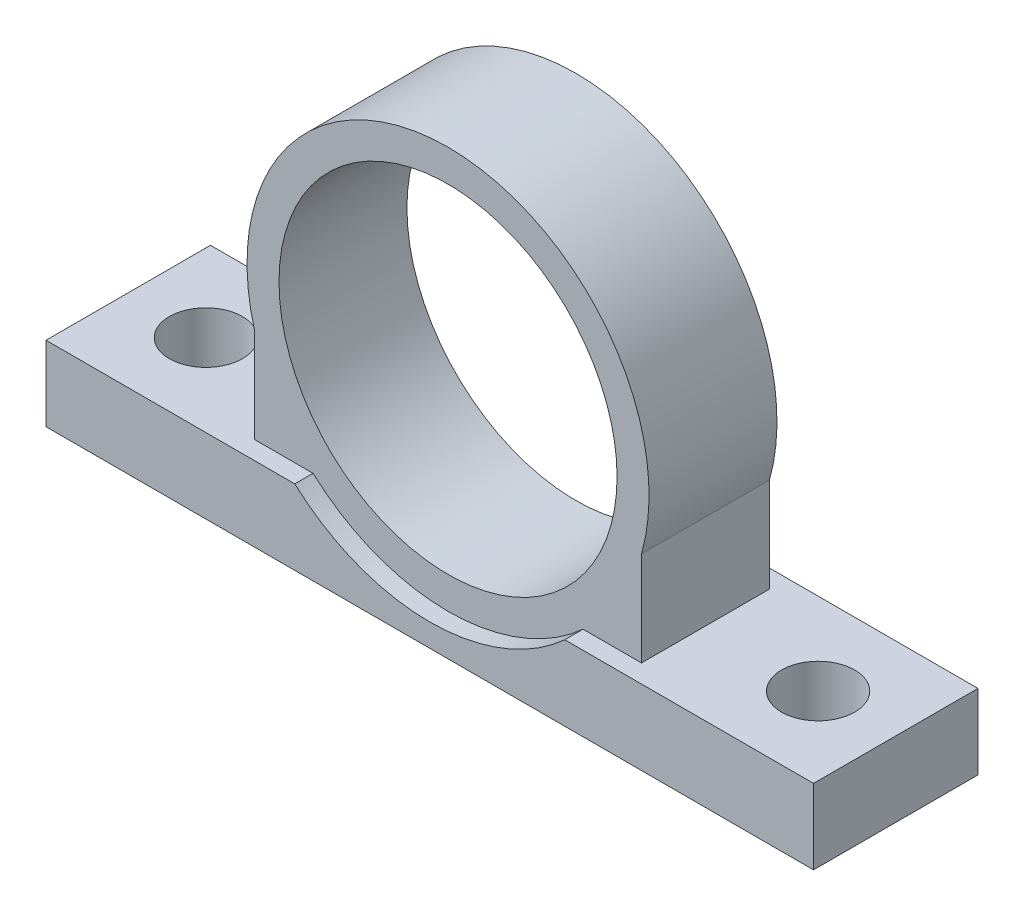
from build123d import *

# Parameters (mm, degrees)
CROQUIS1_R              = 18.5
SALIENTE_EXTRUIR1_DEPTH = 18
CROQUIS2_R              = 17.5
CORTAR_EXTRUIR1_DEPTH   = 2
CROQUIS3_R              = 4
CORTAR_EXTRUIR2_DEPTH   = 9.2


with BuildPart() as part:
    # Croquis1 → Saliente-Extruir1 (new body)
    with BuildSketch(Plane.XY):
        with BuildLine():
            Line((0, 0), (-84, 0))
            Line((-84, 0), (-84, 8.2))
            Line((-84, 8.2), (-63.175317255, 8.2))
            Line((-63.175317255, 8.2), (-63.175317255, 18.532928764))
            ThreePointArc((-63.175317255, 18.532928764), (-42, 46.5), (-20.824682745, 18.532928764))
            Line((-20.824682745, 18.532928764), (-20.824682745, 8.2))
            Line((-20.824682745, 8.2), (0, 8.2))
            Line((0, 8.2), (0, 0))
        make_face()
        with Locations((-42, 24.5)):
            Circle(CROQUIS1_R, mode=Mode.SUBTRACT)
    extrude(amount=SALIENTE_EXTRUIR1_DEPTH)

    # Croquis2 → Cortar-Extruir1 (cut)
    with BuildSketch(Plane.XY.offset(18)):
        with BuildLine():
            Line((-20.824682745, 8.2), (-27.224682745, 8.2))
            ThreePointArc((-27.224682745, 8.2), (-42, 2.5), (-56.775317255, 8.2))
            Line((-56.775317255, 8.2), (-63.175317255, 8.2))
            Line((-63.175317255, 8.2), (-63.175317255, 18.532928764))
            ThreePointArc((-63.175317255, 18.532928764), (-42, 46.5), (-20.824682745, 18.532928764))
            Line((-20.824682745, 18.532928764), (-20.824682745, 8.2))
        make_face()
        with Locations((-42, 24.5)):
            Circle(CROQUIS2_R, mode=Mode.SUBTRACT)
    cortar_extruir1 = extrude(amount=-CORTAR_EXTRUIR1_DEPTH, mode=Mode.SUBTRACT)

    # Simetría1: Cortar-Extruir1 across plane
    add(cortar_extruir1.mirror(Plane.XY.offset(9)), mode=Mode.SUBTRACT)

    # Croquis3 → Cortar-Extruir2 (cut, through all)
    with BuildSketch(Plane(origin=(0, 8.2, 0), x_dir=(1, 0, 0), z_dir=(0, 1, 0))):
        with Locations((-8.5, -9)):
            Circle(CROQUIS3_R)
    cortar_extruir2 = extrude(amount=-CORTAR_EXTRUIR2_DEPTH, mode=Mode.SUBTRACT)

    # Simetría2: Cortar-Extruir2 across plane
    add(cortar_extruir2.mirror(Plane(origin=(-42, 0, 0), x_dir=(0, 0, 1), z_dir=(1, 0, 0))), mode=Mode.SUBTRACT)


solid = part.part
